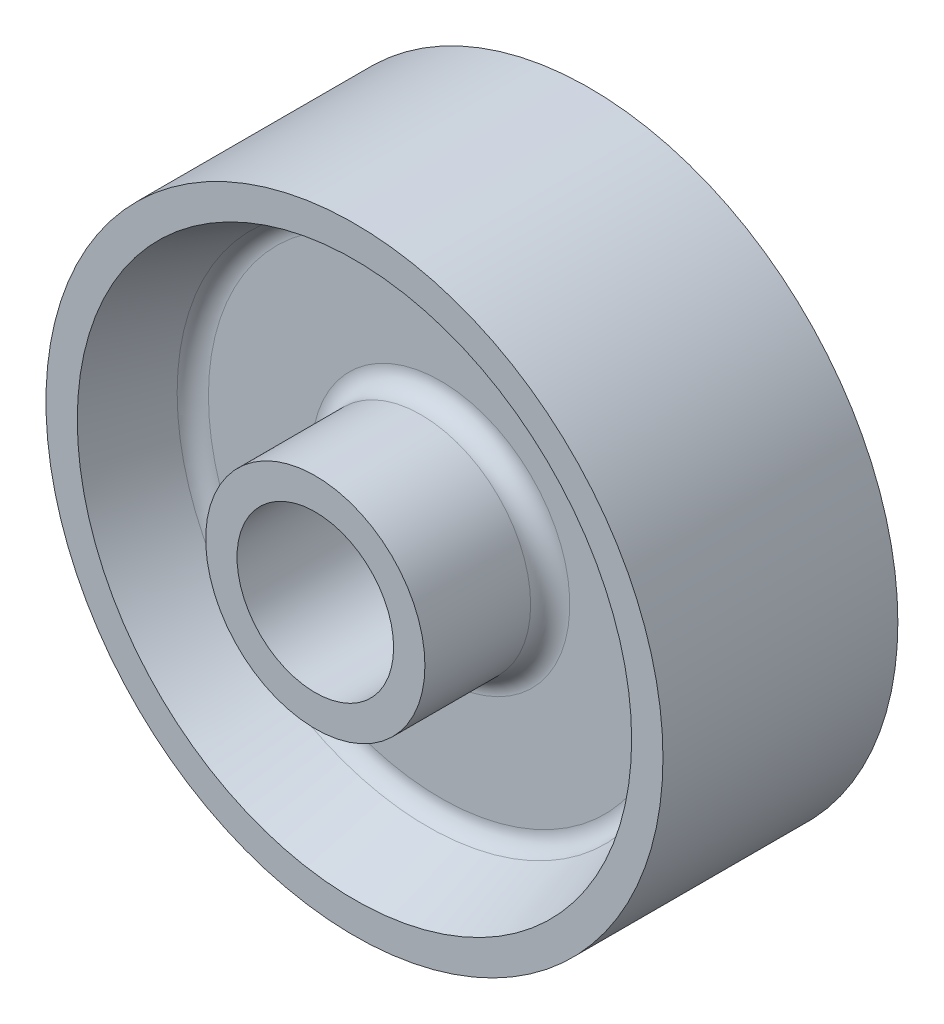
from build123d import *

# Parameters (mm, degrees)
FILLET1_R = 3.175
FILLET2_R = 3.175
FILLET3_R = 3.175
FILLET4_R = 3.175


with BuildPart() as part:
    # Sketch1 → Revolve1 (revolve)
    with BuildSketch(Plane(origin=(0, 0, 0), x_dir=(0, 0, -1), z_dir=(1, 0, 0))):
        Polygon((-25.4, 12.7), (25.4, 12.7), (25.4, 17.78), (5.08, 17.78), (5.08, 39.878), (19.05, 44.958), (19.05, 50.038), (-19.05, 50.038), (-19.05, 44.958), (-5.08, 39.878), (-5.08, 17.78), (-25.4, 17.78), align=None)
    revolve(axis=Axis((0, 0, 55.673126484), (0, 0, -1)))

    # Fillet1
    fillet1_edges = [part.edges().sort_by_distance(p)[0] for p in [
        (0, -17.78, 5.08),
    ]]
    fillet(fillet1_edges, radius=FILLET1_R)

    # Fillet2
    fillet2_edges = [part.edges().sort_by_distance(p)[0] for p in [
        (0, -39.878, 5.08),
    ]]
    fillet(fillet2_edges, radius=FILLET2_R)

    # Fillet3
    fillet3_edges = [part.edges().sort_by_distance(p)[0] for p in [
        (0, -17.78, -5.08),
    ]]
    fillet(fillet3_edges, radius=FILLET3_R)

    # Fillet4
    fillet4_edges = [part.edges().sort_by_distance(p)[0] for p in [
        (0, -39.878, -5.08),
    ]]
    fillet(fillet4_edges, radius=FILLET4_R)


solid = part.part
